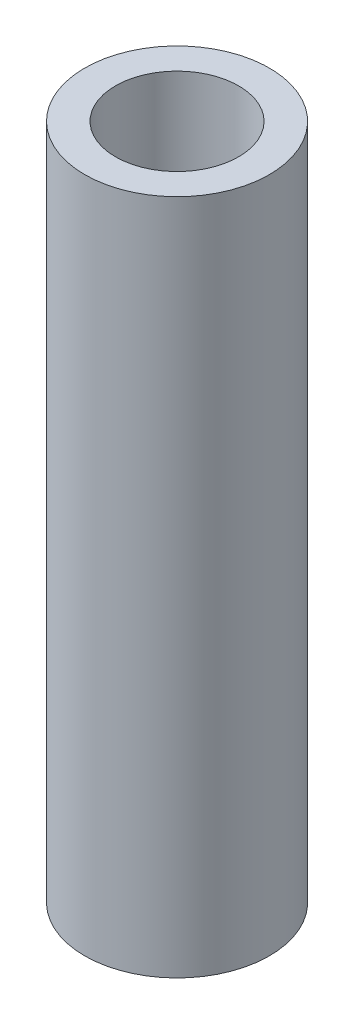
from build123d import *

# Parameters (mm, degrees)
SKETCH3_R                        = 2.38125
BOSS_EXTRUDE3_DEPTH              = 17.45
F_1_8_0_125_DIAMETER_HOLE1_D     = 3.175
F_1_8_0_125_DIAMETER_HOLE1_DEPTH = 17.449999898


with BuildPart() as part:
    # Sketch3 → Boss-Extrude3 (new body)
    with BuildSketch(Plane(origin=(0, -22.882660102, 0), x_dir=(1, 0, 0), z_dir=(0, 1, 0))):
        Circle(SKETCH3_R)
    extrude(amount=-BOSS_EXTRUDE3_DEPTH)

    # 1/8 (0.125) Diameter Hole1
    with Locations(Plane(origin=(0, -22.882660102, 0), x_dir=(1, 0, 0), z_dir=(0, 1, 0))):
        with Locations((0, 0)):
            Hole(F_1_8_0_125_DIAMETER_HOLE1_D / 2, depth=F_1_8_0_125_DIAMETER_HOLE1_DEPTH)


solid = part.part
